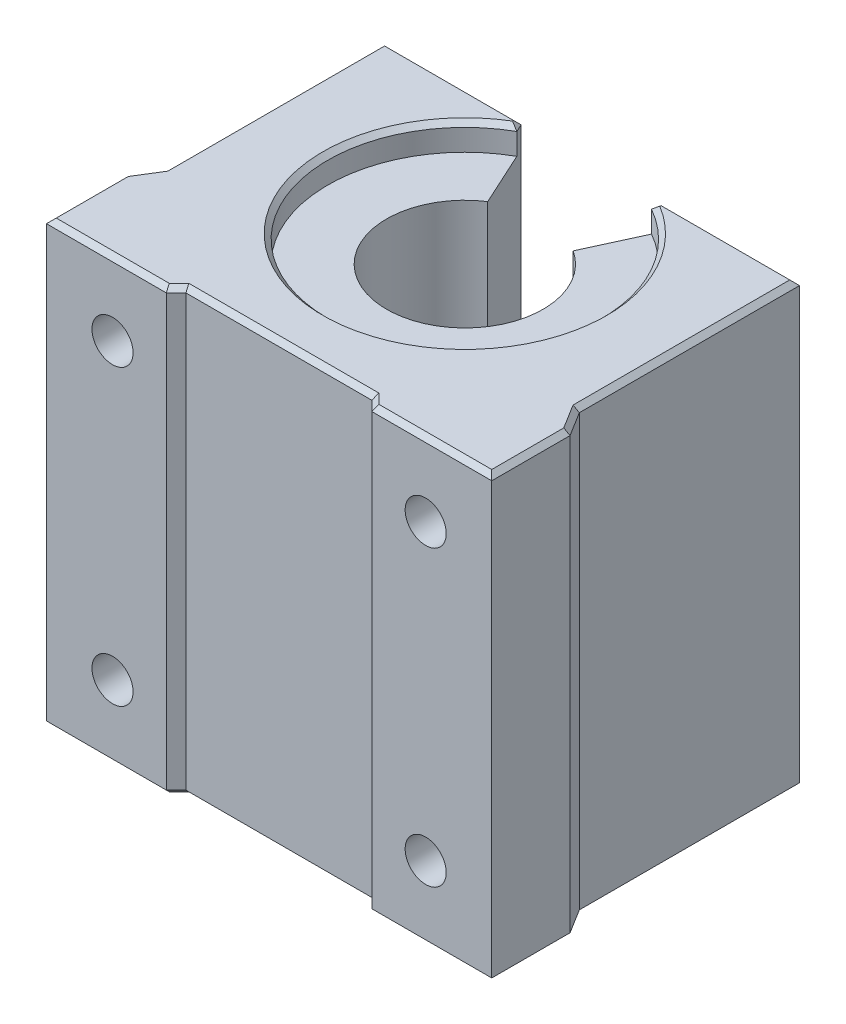
from build123d import *

# Parameters (mm, degrees)
SKETCH1_W                 = 45.5
SKETCH1_H                 = 45
BOSS_EXTRUDE1_DEPTH       = 33
CUT_EXTRUDE1_DEPTH        = 46
CUT_EXTRUDE2_DEPTH        = 46
CUT_EXTRUDE4_DEPTH        = 46
M5X0_8_TAPPED_HOLE1_D     = 4.2
M5X0_8_TAPPED_HOLE1_DEPTH = 15.6
M5X0_8_TAPPED_HOLE1_TIP   = 1.2618073
CHAMFER1_SIZE             = 0.5


with BuildPart() as part:
    # Sketch1 → Boss-Extrude1 (new body)
    with BuildSketch(Plane(origin=(0, 0, -13.05), x_dir=(-1, 0, 0), z_dir=(0, 0, -1))):
        Rectangle(SKETCH1_W, SKETCH1_H)
    extrude(amount=-BOSS_EXTRUDE1_DEPTH)

    # Sketch2 → Cut-Extrude1 (cut, through all)
    with BuildSketch(Plane(origin=(0, 22.5, 0), x_dir=(-1, 0, 0), z_dir=(0, 1, 0))):
        Polygon((-21.2, -13.05), (-21.2, 9.45), (-22.75, 11.95), (-22.75, -13.05), align=None)
    cut_extrude1 = extrude(amount=-CUT_EXTRUDE1_DEPTH, mode=Mode.SUBTRACT)

    # Mirror1: Cut-Extrude1 across plane
    add(cut_extrude1.mirror(Plane(origin=(0, 0, 0), x_dir=(0, 0, 1), z_dir=(1, 0, 0))), mode=Mode.SUBTRACT)

    # Sketch3 → Cut-Extrude2 (cut, through all)
    with BuildSketch(Plane(origin=(0, 22.5, 0), x_dir=(-1, 0, 0), z_dir=(0, 1, 0))):
        Polygon((-10.5, 19.95), (-9.5, 18.95), (9.5, 18.95), (10.5, 19.95), align=None)
    extrude(amount=-CUT_EXTRUDE2_DEPTH, mode=Mode.SUBTRACT)

    # Sketch5 → Cut-Extrude4 (cut, through all)
    with BuildSketch(Plane(origin=(0, 22.5, 0), x_dir=(-1, 0, 0), z_dir=(0, 1, 0))):
        Polygon((-7.250013867, -13.05), (7.250013867, -13.05), (0, 2.768211411), align=None)
    extrude(amount=-CUT_EXTRUDE4_DEPTH, mode=Mode.SUBTRACT)

    # Sketch6 → Cut-Revolve1 (revolve, cut)
    with BuildSketch(Plane.XY.offset(-0.05)):
        Polygon((14, 22.5), (0, 22.5), (0, -22.5), (14, -22.5), (14, -19.8), (8, -19.8), (8, 19.8), (14, 19.8), align=None)
    revolve(axis=Axis((0, 22.5, -0.05), (0, -1, 0)), mode=Mode.SUBTRACT)

    # M5x0.8 Tapped Hole1
    with Locations(Plane.XY.offset(19.95)):
        with Locations((-16, -15), (16, 15), (16, -15), (-16, 15)):
            Hole(M5X0_8_TAPPED_HOLE1_D / 2, depth=M5X0_8_TAPPED_HOLE1_DEPTH)
            with Locations((0, 0, -(M5X0_8_TAPPED_HOLE1_DEPTH + M5X0_8_TAPPED_HOLE1_TIP / 2))):  # 118° drill point
                Cone(0, M5X0_8_TAPPED_HOLE1_D / 2, M5X0_8_TAPPED_HOLE1_TIP, mode=Mode.SUBTRACT)

    # Chamfer1
    chamfer1_edges = [part.edges().sort_by_distance(p)[0] for p in [
        (14.225006933, -22.5, -13.05),
        (16.625, -22.5, 19.95),
        (21.975, -22.5, 10.7),
        (21.2, -22.5, -1.8),
        (21.2, 22.5, -1.8),
        (21.975, 22.5, 10.7),
        (-14.225006933, 22.5, -13.05),
        (-21.2, 22.5, -1.8),
        (-21.975, 22.5, 10.7),
        (-21.2, -22.5, -1.8),
        (-21.975, -22.5, 10.7),
        (-16.625, -22.5, 19.95),
        (16.625, 22.5, 19.95),
        (-10, -22.5, 19.45),
        (0, -22.5, 18.95),
        (10, -22.5, 19.45),
        (10, 22.5, 19.45),
        (0, 22.5, 18.95),
        (-10, 22.5, 19.45),
        (-14.225006933, -22.5, -13.05),
        (14.225006933, 22.5, -13.05),
        (-7.065034848, -22.5, -12.646409431),
        (-7.065034848, 22.5, -12.646409431),
        (7.065034848, 22.5, -12.646409431),
        (7.065034848, -22.5, -12.646409431),
        (0, 22.5, 13.95),
        (0, -22.5, 13.95),
        (-22.75, -22.5, 15.95),
        (22.75, -22.5, 15.95),
        (22.75, 22.5, 15.95),
        (-22.75, 22.5, 15.95),
        (-16.625, 22.5, 19.95),
    ]]
    chamfer(chamfer1_edges, length=CHAMFER1_SIZE)


solid = part.part
